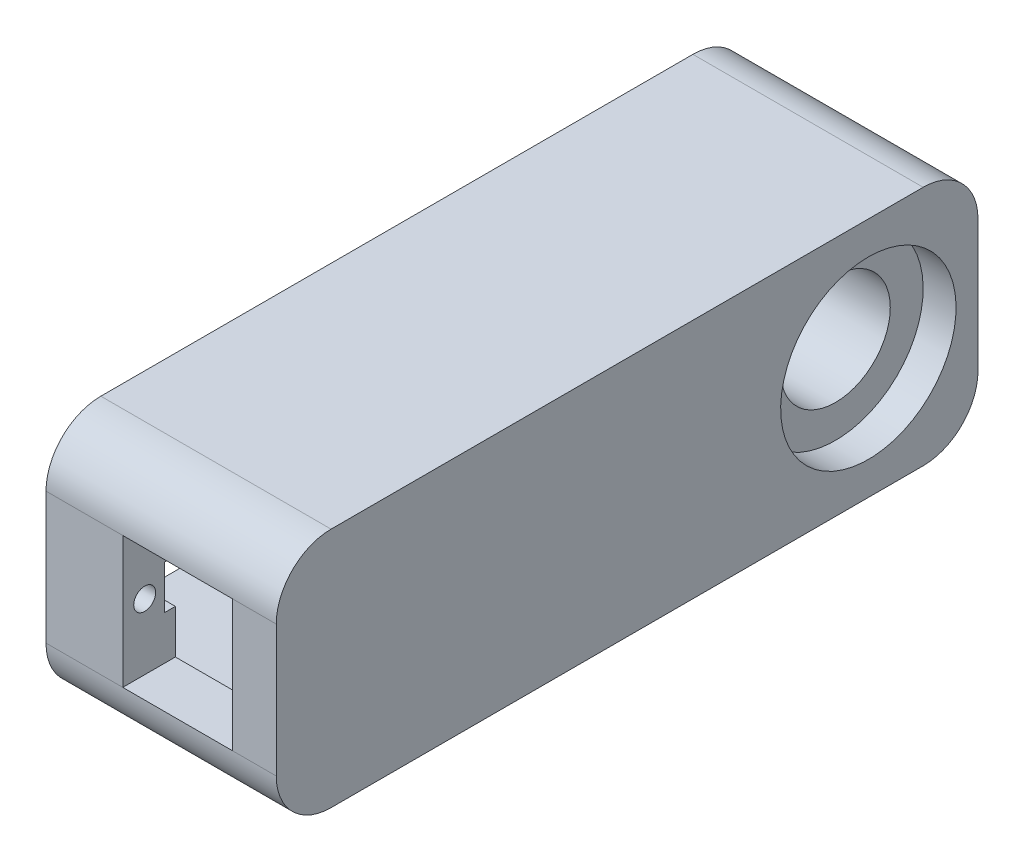
from build123d import *

# Parameters (mm, degrees)
SKETCH1_W                = 64
SKETCH1_H                = 22
BOSS_EXTRUDE1_DEPTH      = 4
BOSS_EXTRUDE1_DEPTH_BACK = 17
SKETCH2_W                = 10
SKETCH2_H                = 12
CUT_EXTRUDE1_DEPTH       = 5
SKETCH3_R                = 1
CUT_EXTRUDE2_DEPTH       = 7
SKETCH4_R                = 5
CUT_EXTRUDE3_DEPTH       = 21
CUT_EXTRUDE4_START       = -17
SKETCH7_W                = 22.400000327
SKETCH7_H                = 12.400000179
CUT_EXTRUDE4_DEPTH       = 17
CUT_EXTRUDE5_REACH       = 9
SKETCH8_W                = 1
SKETCH8_H                = 4
CUT_EXTRUDE7_DEPTH       = 21
SKETCH9_R                = 8
CUT_EXTRUDE6_DEPTH       = 3


with BuildPart() as part:
    # Sketch1 → Boss-Extrude1 (new body, two sides)
    with BuildSketch(Plane(origin=(54.112238255, 0, 0), x_dir=(0, 0, -1), z_dir=(1, 0, 0))) as boss_extrude1_sk:
        with Locations((44.500000075, 65.042436513)):
            Rectangle(SKETCH1_W, SKETCH1_H)
    extrude(amount=BOSS_EXTRUDE1_DEPTH)
    extrude(boss_extrude1_sk.sketch, amount=-BOSS_EXTRUDE1_DEPTH_BACK)

    # Sketch2 → Cut-Extrude1 (cut)
    with BuildSketch(Plane.XY.offset(-12.500000075)):
        with Locations((49.112238255, 65.042436513)):
            Rectangle(SKETCH2_W, SKETCH2_H)
    extrude(amount=-CUT_EXTRUDE1_DEPTH, mode=Mode.SUBTRACT)

    # Sketch3 → Cut-Extrude2 (cut)
    with BuildSketch(Plane.ZY.offset(-37.112238255)):
        with Locations((-14.499999836, 65.042436513)):
            Circle(SKETCH3_R)
        with Locations((-42.500000313, 65.042436513)):
            Circle(SKETCH3_R)
    extrude(amount=-CUT_EXTRUDE2_DEPTH, mode=Mode.SUBTRACT)

    # Sketch4 → Cut-Extrude3 (cut)
    with BuildSketch(Plane.ZY.offset(-37.112238255)):
        with Locations((-66.500000075, 65.042436513)):
            Circle(SKETCH4_R)
    extrude(amount=-CUT_EXTRUDE3_DEPTH, mode=Mode.SUBTRACT)

    # Sketch7 → Cut-Extrude4 (cut)
    with BuildSketch(Plane.ZY.offset(-37.112238255).offset(CUT_EXTRUDE4_START)):
        with Locations((-28.500000075, 65.042436514)):
            Rectangle(SKETCH7_W, SKETCH7_H)
    extrude(amount=CUT_EXTRUDE4_DEPTH, mode=Mode.SUBTRACT)

    # Sketch8 → Cut-Extrude5 (cut, up to next)
    with BuildSketch(Plane(origin=(44.112238255, 0, 0), x_dir=(0, 0, -1), z_dir=(1, 0, 0)), mode=Mode.PRIVATE) as cut_extrude5_sk1:
        with Locations((16.799999911, 65.042436513)):
            Rectangle(SKETCH8_W, SKETCH8_H)
    cut_extrude5_tool1 = extrude(cut_extrude5_sk1.sketch, amount=-CUT_EXTRUDE5_REACH, mode=Mode.PRIVATE) & part.part
    add(cut_extrude5_tool1.solids().sort_by_distance((44.112238, 65.042437, -16.8))[0], mode=Mode.SUBTRACT)

    # Sketch10 → Cut-Extrude7 (cut)
    with BuildSketch(Plane(origin=(58.112238255, 0, 0), x_dir=(0, 0, -1), z_dir=(1, 0, 0))):
        with BuildLine():
            ThreePointArc((12.500000075, 71.042436513), (13.964466169, 74.577970419), (17.500000075, 76.042436513))
            Line((17.500000075, 76.042436513), (12.500000075, 76.042436513))
            Line((12.500000075, 76.042436513), (12.500000075, 71.042436513))
        make_face()
        with BuildLine():
            ThreePointArc((71.500000075, 76.042436513), (75.03553398, 74.577970419), (76.500000075, 71.042436513))
            Line((76.500000075, 71.042436513), (76.500000075, 76.042436513))
            Line((76.500000075, 76.042436513), (71.500000075, 76.042436513))
        make_face()
        with BuildLine():
            Line((76.500000075, 54.042436513), (76.500000075, 59.042436513))
            ThreePointArc((76.500000075, 59.042436513), (75.03553398, 55.506902607), (71.500000075, 54.042436513))
            Line((71.500000075, 54.042436513), (76.500000075, 54.042436513))
        make_face()
        with BuildLine():
            Line((12.500000075, 54.042436513), (17.500000075, 54.042436513))
            ThreePointArc((17.500000075, 54.042436513), (13.964466169, 55.506902607), (12.500000075, 59.042436513))
            Line((12.500000075, 59.042436513), (12.500000075, 54.042436513))
        make_face()
    extrude(amount=-CUT_EXTRUDE7_DEPTH, mode=Mode.SUBTRACT)

    # Sketch9 → Cut-Extrude6 (cut)
    with BuildSketch(Plane(origin=(58.112238255, 0, 0), x_dir=(0, 0, -1), z_dir=(1, 0, 0))):
        with Locations((66.500000075, 65.042436513)):
            Circle(SKETCH9_R)
    extrude(amount=-CUT_EXTRUDE6_DEPTH, mode=Mode.SUBTRACT)


solid = part.part
